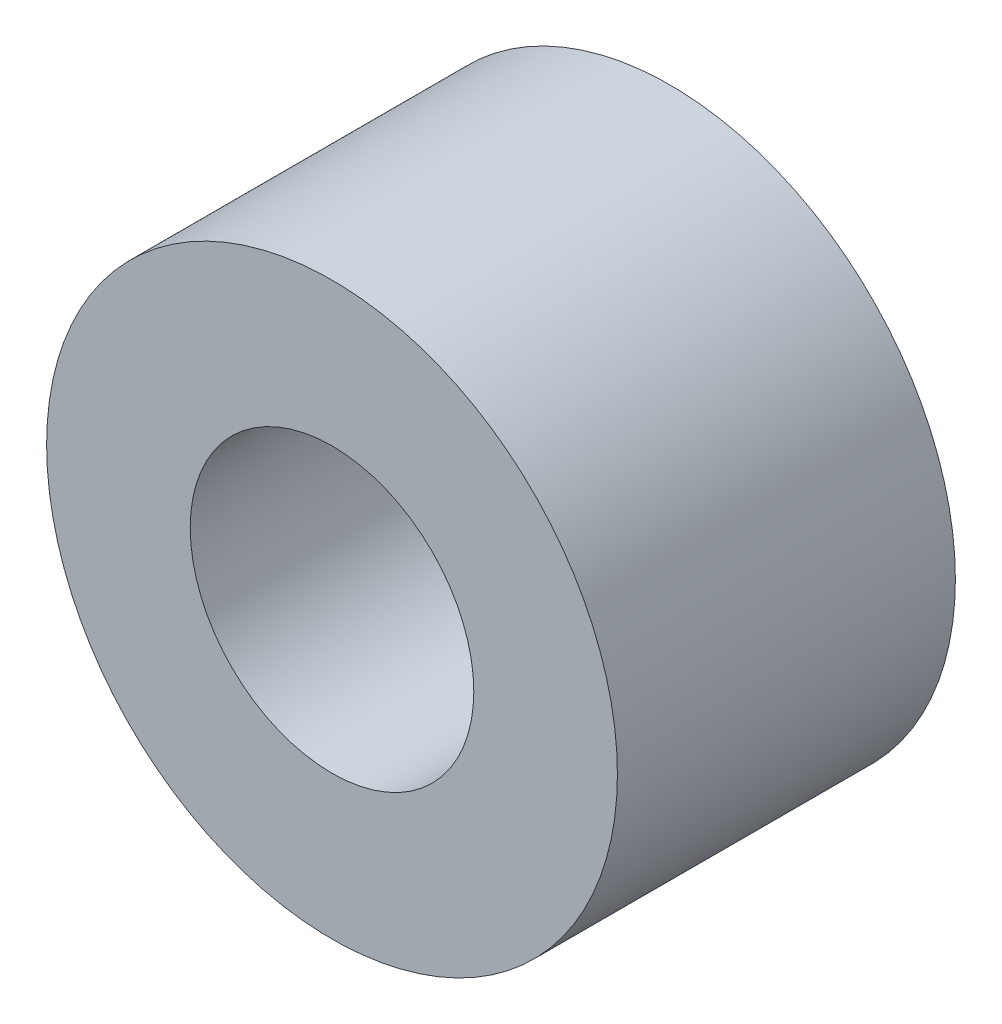
from build123d import *

# Parameters (mm, degrees)
SKETCH1_R           = 15.2
SKETCH1_R_2         = 7.551278112
BOSS_EXTRUDE1_DEPTH = 18


with BuildPart() as part:
    # Sketch1 → Boss-Extrude1 (new body)
    with BuildSketch(Plane.XY):
        Circle(SKETCH1_R)
        Circle(SKETCH1_R_2, mode=Mode.SUBTRACT)
    extrude(amount=BOSS_EXTRUDE1_DEPTH)


solid = part.part
